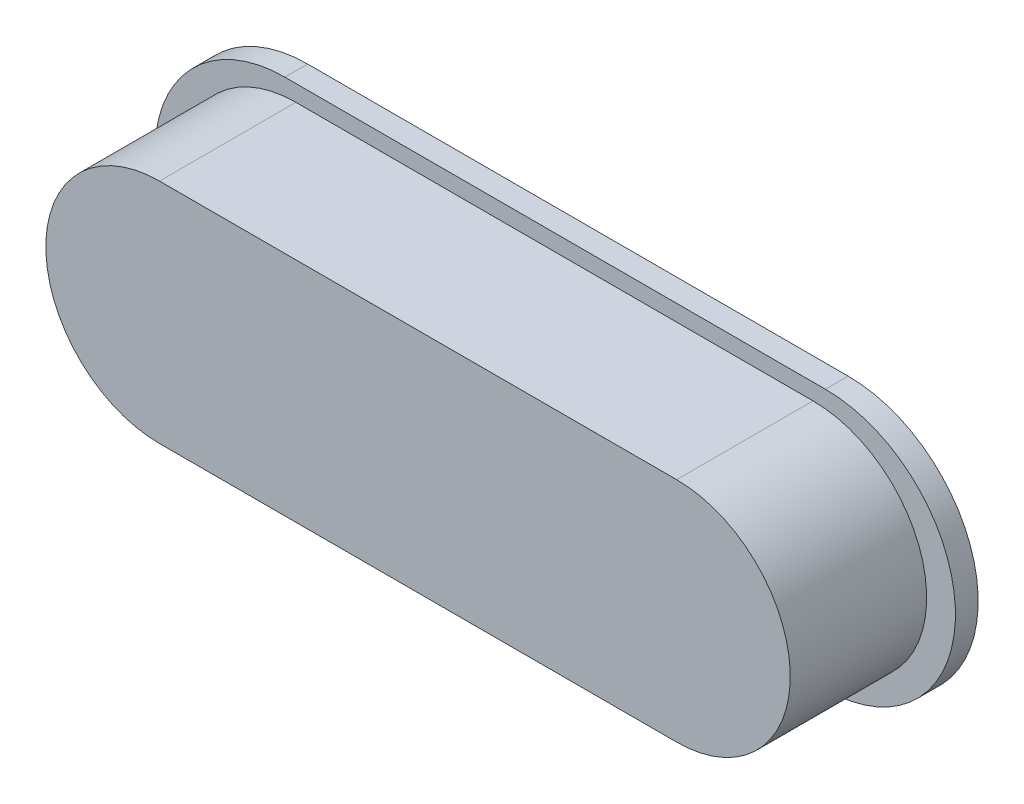
from build123d import *

# Parameters (mm, degrees)
BOSS_EXTRUDE1_DEPTH = 12
CUT_EXTRUDE1_DEPTH  = 8
BOSS_EXTRUDE2_START = -12
BOSS_EXTRUDE2_DEPTH = 2


with BuildPart() as part:
    # Sketch1 → Boss-Extrude1 (new body)
    with BuildSketch(Plane.XY):
        with BuildLine():
            Line((-22.75, 10), (22.75, 10))
            ThreePointArc((22.75, 10), (32.75, 0), (22.75, -10))
            Line((22.75, -10), (-22.75, -10))
            ThreePointArc((-22.75, -10), (-32.75, 0), (-22.75, 10))
        make_face()
    extrude(amount=BOSS_EXTRUDE1_DEPTH)

    # Sketch2 → Cut-Extrude1 (cut)
    with BuildSketch(Plane.XY):
        with BuildLine():
            Line((-23.5, 8), (23.5, 8))
            ThreePointArc((23.5, 8), (31.5, 0), (23.5, -8))
            Line((23.5, -8), (-23.5, -8))
            ThreePointArc((-23.5, -8), (-31.5, 0), (-23.5, 8))
        make_face()
    extrude(amount=CUT_EXTRUDE1_DEPTH, mode=Mode.SUBTRACT)


with BuildPart() as body_2:
    # Sketch3 → Boss-Extrude2 (new body)
    with BuildSketch(Plane.XY.offset(12).offset(BOSS_EXTRUDE2_START)):
        with BuildLine():
            Line((-23.717058044, 11.43482794), (23.847510299, 11.43482794))
            ThreePointArc((23.847510299, 11.43482794), (35.28233824, 0), (23.847510299, -11.43482794))
            Line((23.847510299, -11.43482794), (-23.717058044, -11.43482794))
            ThreePointArc((-23.717058044, -11.43482794), (-35.151885985, 0), (-23.717058044, 11.43482794))
        make_face()
        with BuildLine():
            Line((-22.75, 8), (23.5, 8))
            ThreePointArc((23.5, 8), (31.5, 0), (23.5, -8))
            Line((23.5, -8), (-22.75, -8))
            ThreePointArc((-22.75, -8), (-30.75, 0), (-22.75, 8))
        make_face(mode=Mode.SUBTRACT)
    extrude(amount=-BOSS_EXTRUDE2_DEPTH)


solid = Compound([part.part, body_2.part])
